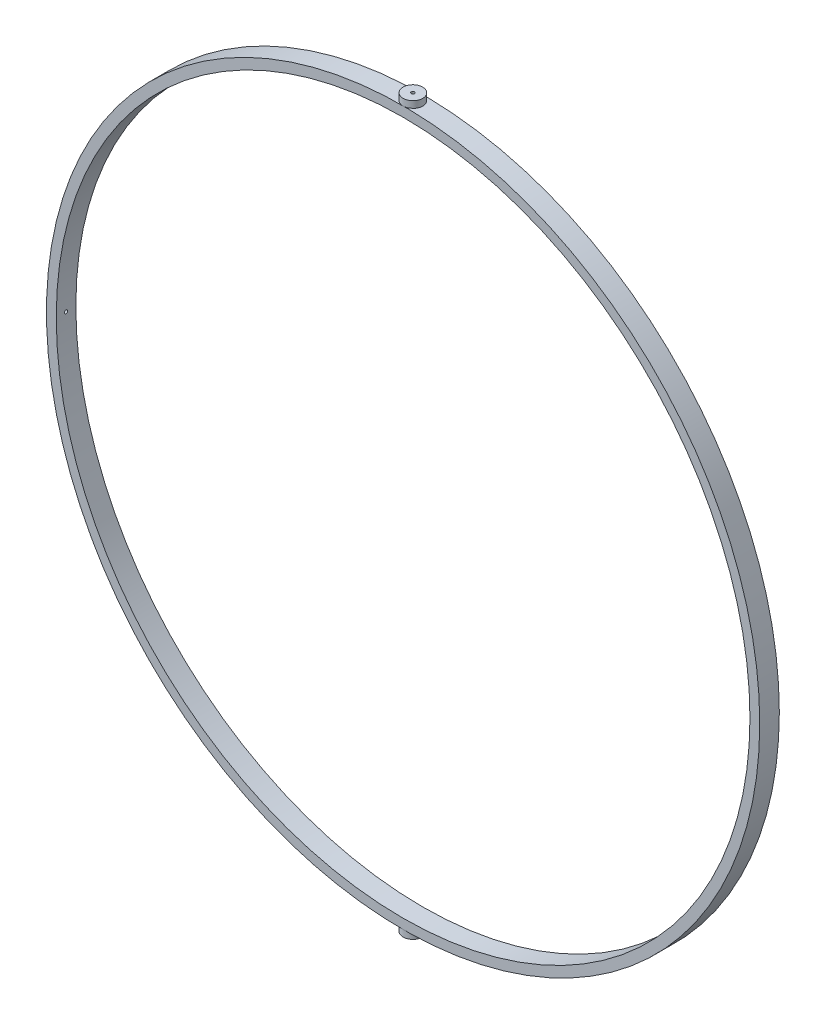
from build123d import *

# Parameters (mm, degrees)
SKETCH1_R           = 109.24716621
SKETCH1_R_2         = 106.24716621
BOSS_EXTRUDE1_DEPTH = 6
SKETCH3_R           = 3
SKETCH3_R_2         = 0.5
BOSS_EXTRUDE2_DEPTH = 5
SKETCH4_R           = 3
SKETCH4_R_2         = 0.5
BOSS_EXTRUDE3_DEPTH = 5
SKETCH8_R           = 0.5
CUT_EXTRUDE7_DEPTH  = 3
SKETCH9_R           = 0.5
CUT_EXTRUDE8_DEPTH  = 3


with BuildPart() as part:
    # Sketch1 → Boss-Extrude1 (new body)
    with BuildSketch(Plane.XY):
        Circle(SKETCH1_R)
        Circle(SKETCH1_R_2, mode=Mode.SUBTRACT)
    extrude(amount=BOSS_EXTRUDE1_DEPTH)

    # Sketch8 → Cut-Extrude7 (cut)
    with BuildSketch(Plane.ZY.offset(-108.24716621)):
        with Locations((3, 0)):
            Circle(SKETCH8_R)
    extrude(amount=CUT_EXTRUDE7_DEPTH, mode=Mode.SUBTRACT)

    # Sketch9 → Cut-Extrude8 (cut)
    with BuildSketch(Plane.ZY.offset(108.24716621)):
        with Locations((3, 0)):
            Circle(SKETCH9_R)
    extrude(amount=-CUT_EXTRUDE8_DEPTH, mode=Mode.SUBTRACT)


with BuildPart() as body_2:
    # Sketch3 → Boss-Extrude2 (new body)
    with BuildSketch(Plane(origin=(0, -106.24716621, 0), x_dir=(1, 0, 0), z_dir=(0, 1, 0))):
        with Locations((0, -3)):
            Circle(SKETCH3_R)
        with Locations((0, -3)):
            Circle(SKETCH3_R_2, mode=Mode.SUBTRACT)
    extrude(amount=-BOSS_EXTRUDE2_DEPTH)


with BuildPart() as body_3:
    # Sketch4 → Boss-Extrude3 (new body)
    with BuildSketch(Plane(origin=(0, 106.24716621, 0), x_dir=(1, 0, 0), z_dir=(0, 1, 0))):
        with Locations((0, -3)):
            Circle(SKETCH4_R)
        with Locations((0, -3)):
            Circle(SKETCH4_R_2, mode=Mode.SUBTRACT)
    extrude(amount=BOSS_EXTRUDE3_DEPTH)


solid = Compound([part.part, body_2.part, body_3.part])
